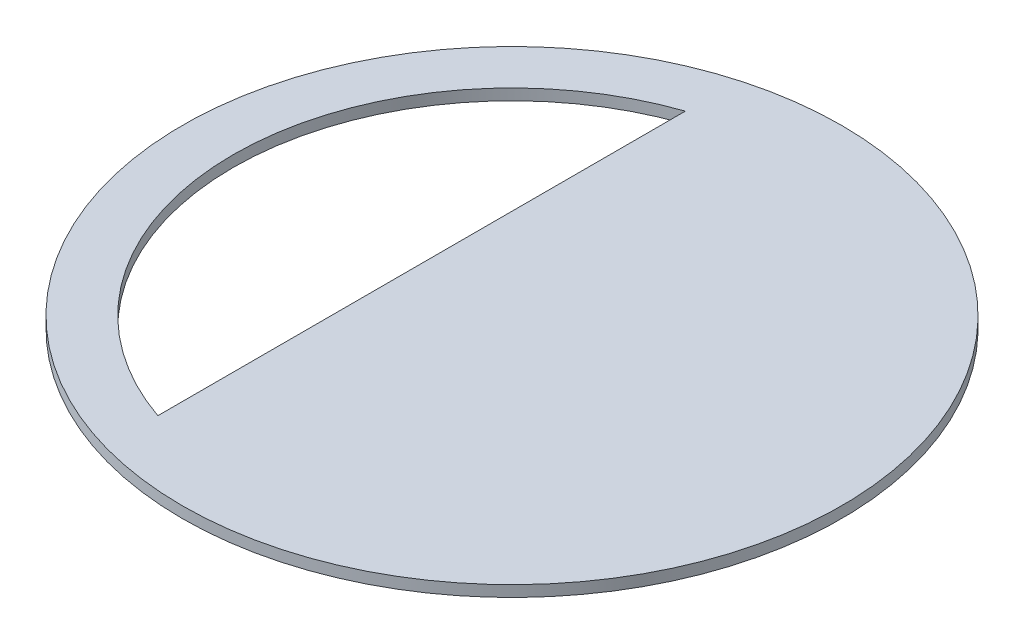
from build123d import *

# Parameters (mm, degrees)
SKETCH3_R           = 60.198
BOSS_EXTRUDE1_DEPTH = 2.032
CUT_EXTRUDE1_DEPTH  = 3.032


with BuildPart() as part:
    # Sketch3 → Boss-Extrude1 (new body)
    with BuildSketch(Plane(origin=(0, 0, 0), x_dir=(1, 0, 0), z_dir=(0, 1, 0))):
        Circle(SKETCH3_R)
    extrude(amount=BOSS_EXTRUDE1_DEPTH)

    # Sketch6 → Cut-Extrude1 (cut, through all)
    with BuildSketch(Plane(origin=(0, 2.032, 0), x_dir=(1, 0, 0), z_dir=(0, 1, 0))):
        with BuildLine():
            Line((-16.51, -48.176542311), (-16.51, 48.176542311))
            ThreePointArc((-16.51, 48.176542311), (-50.927, 0), (-16.51, -48.176542311))
        make_face()
    extrude(amount=-CUT_EXTRUDE1_DEPTH, mode=Mode.SUBTRACT)


solid = part.part
